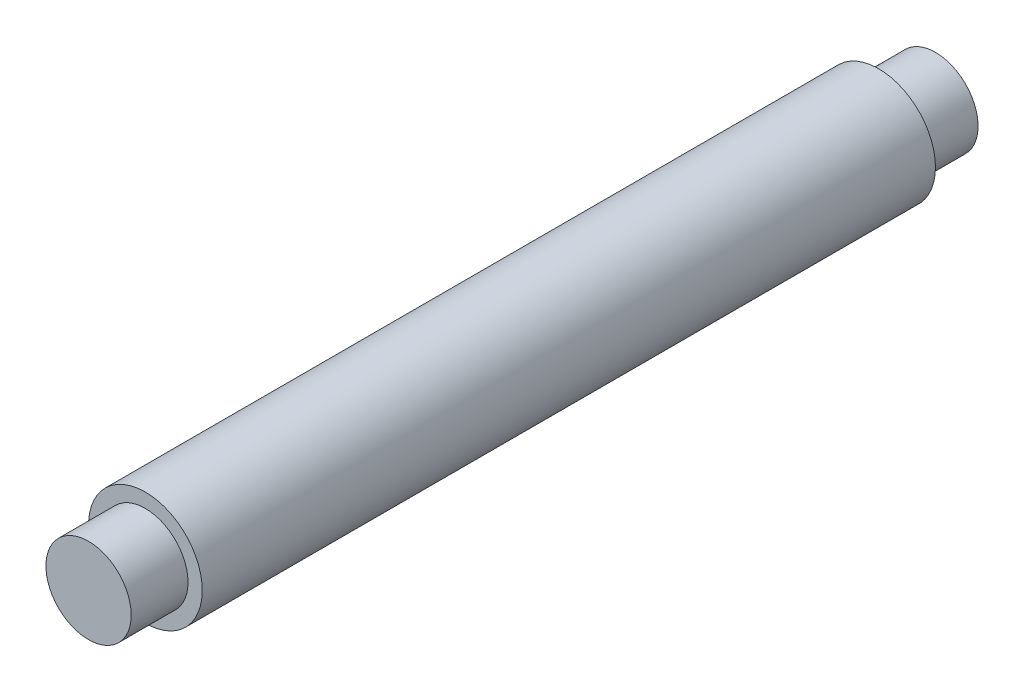
from build123d import *

# Parameters (mm, degrees)
SKETCH1_R           = 20
BOSS_EXTRUDE1_DEPTH = 258
SKETCH2_R           = 15
BOSS_EXTRUDE2_DEPTH = 20
SKETCH3_R           = 15
BOSS_EXTRUDE3_DEPTH = 20


with BuildPart() as part:
    # Sketch1 → Boss-Extrude1 (new body)
    with BuildSketch(Plane.XY):
        Circle(SKETCH1_R)
    extrude(amount=BOSS_EXTRUDE1_DEPTH)

    # Sketch2 → Boss-Extrude2 (add)
    with BuildSketch(Plane.XY.offset(258)):
        Circle(SKETCH2_R)
    extrude(amount=BOSS_EXTRUDE2_DEPTH)

    # Sketch3 → Boss-Extrude3 (add)
    with BuildSketch(Plane(origin=(0, 0, 0), x_dir=(-1, 0, 0), z_dir=(0, 0, -1))):
        Circle(SKETCH3_R)
    extrude(amount=BOSS_EXTRUDE3_DEPTH)


solid = part.part
